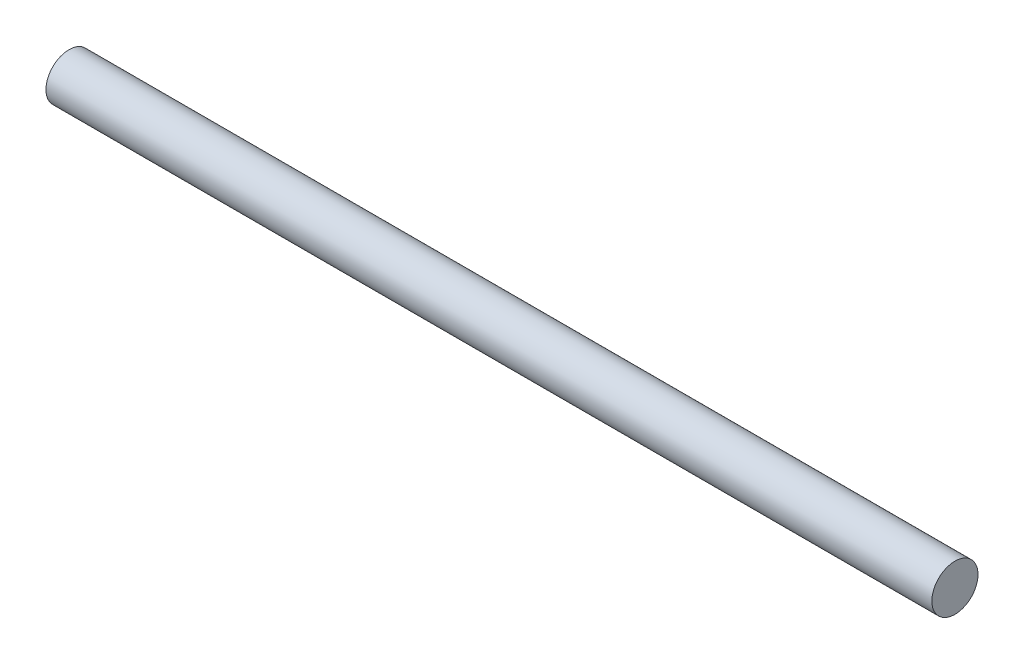
from build123d import *

# Parameters (mm, degrees)
SKETCH1_R           = 2.5
BOSS_EXTRUDE1_DEPTH = 96


with BuildPart() as part:
    # Sketch1 → Boss-Extrude1 (new body)
    with BuildSketch(Plane(origin=(0, 0, 0), x_dir=(0, 0, -1), z_dir=(1, 0, 0))):
        Circle(SKETCH1_R)
    extrude(amount=BOSS_EXTRUDE1_DEPTH)


solid = part.part
